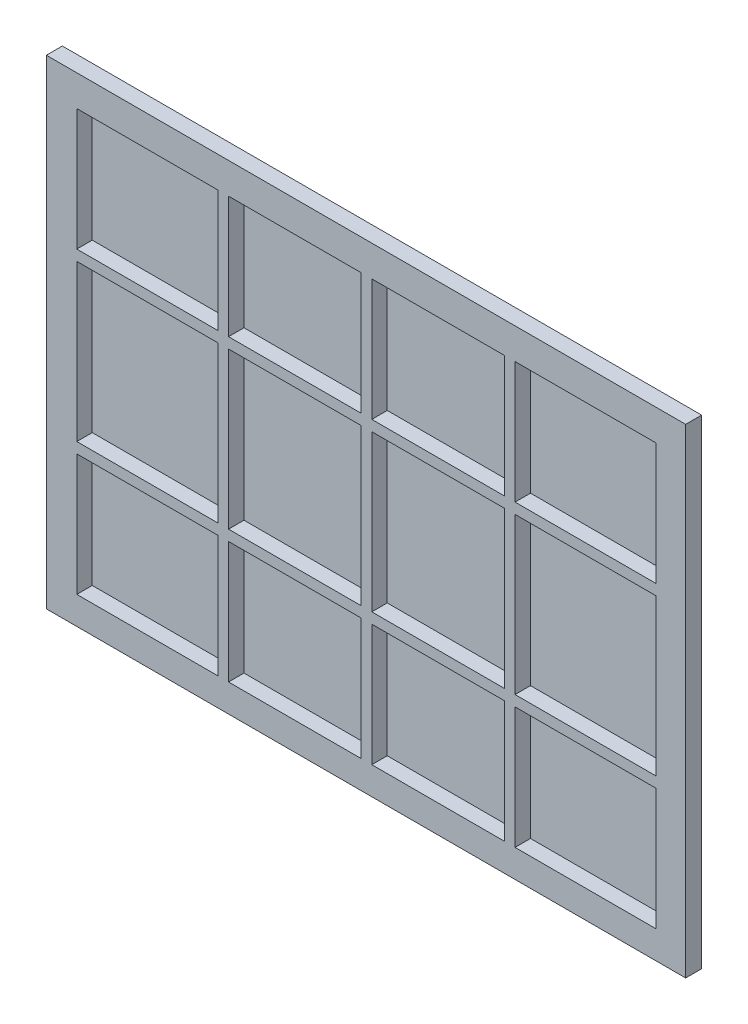
from build123d import *

# Parameters (mm, degrees)
SKETCH2_W           = 1200
SKETCH2_H           = 900
BOSS_EXTRUDE2_DEPTH = 30
SKETCH3_W           = 1087.423470631
SKETCH3_H           = 789.777232946
CUT_EXTRUDE2_DEPTH  = 29
RIB6_REACH          = 1502.3
SKETCH6_WALLS_W     = 20
SKETCH6_WALLS_H     = 3792.377172958
SKETCH6_WALLS_W_2   = 4090.023410643
SKETCH6_WALLS_H_2   = 20


with BuildPart() as part:
    # Sketch2 → Boss-Extrude2 (new body)
    with BuildSketch(Plane.XY):
        with Locations((600, 450)):
            Rectangle(SKETCH2_W, SKETCH2_H)
    extrude(amount=BOSS_EXTRUDE2_DEPTH)

    # Sketch3 → Cut-Extrude2 (cut)
    with BuildSketch(Plane.XY.offset(30)):
        with Locations((600.845585903, 447.040449341)):
            Rectangle(SKETCH3_W, SKETCH3_H)
    extrude(amount=-CUT_EXTRUDE2_DEPTH, mode=Mode.SUBTRACT)

    # Sketch6 walls → Rib6 (add, up to next)
    with BuildSketch(Plane.XY.offset(30), mode=Mode.PRIVATE) as rib6_sk1:
        with Locations((600.845585903, 447.040449341)):
            Rectangle(SKETCH6_WALLS_W, SKETCH6_WALLS_H)
    rib6_tool1 = extrude(rib6_sk1.sketch, amount=-RIB6_REACH, mode=Mode.PRIVATE) - part.part
    # Sketch6 walls → Rib6 (add, up to next)
    with BuildSketch(Plane.XY.offset(30), mode=Mode.PRIVATE) as rib6_sk2:
        with Locations((331.949268904, 447.040449341)):
            Rectangle(SKETCH6_WALLS_W, SKETCH6_WALLS_H)
    rib6_tool2 = extrude(rib6_sk2.sketch, amount=-RIB6_REACH, mode=Mode.PRIVATE) - part.part
    # Sketch6 walls → Rib6 (add, up to next)
    with BuildSketch(Plane.XY.offset(30), mode=Mode.PRIVATE) as rib6_sk3:
        with Locations((600.845585903, 603.473841306)):
            Rectangle(SKETCH6_WALLS_W_2, SKETCH6_WALLS_H_2)
    rib6_tool3 = extrude(rib6_sk3.sketch, amount=-RIB6_REACH, mode=Mode.PRIVATE) - part.part
    # Sketch6 walls → Rib6 (add, up to next)
    with BuildSketch(Plane.XY.offset(30), mode=Mode.PRIVATE) as rib6_sk4:
        with Locations((869.741902901, 447.040449341)):
            Rectangle(SKETCH6_WALLS_W, SKETCH6_WALLS_H)
    rib6_tool4 = extrude(rib6_sk4.sketch, amount=-RIB6_REACH, mode=Mode.PRIVATE) - part.part
    # Sketch6 walls → Rib6 (add, up to next)
    with BuildSketch(Plane.XY.offset(30), mode=Mode.PRIVATE) as rib6_sk5:
        with Locations((600.845585903, 290.607057376)):
            Rectangle(SKETCH6_WALLS_W_2, SKETCH6_WALLS_H_2)
    rib6_tool5 = extrude(rib6_sk5.sketch, amount=-RIB6_REACH, mode=Mode.PRIVATE) - part.part
    add(rib6_tool1.solids().sort_by_distance((600.845585903, 447.040449341, 30))[0])
    add(rib6_tool2.solids().sort_by_distance((331.949268904, 447.040449341, 30))[0])
    add(rib6_tool3.solids().sort_by_distance((600.845585903, 603.473841306, 30))[0])
    add(rib6_tool4.solids().sort_by_distance((869.741902901, 447.040449341, 30))[0])
    add(rib6_tool5.solids().sort_by_distance((600.845585903, 290.607057376, 30))[0])


solid = part.part
